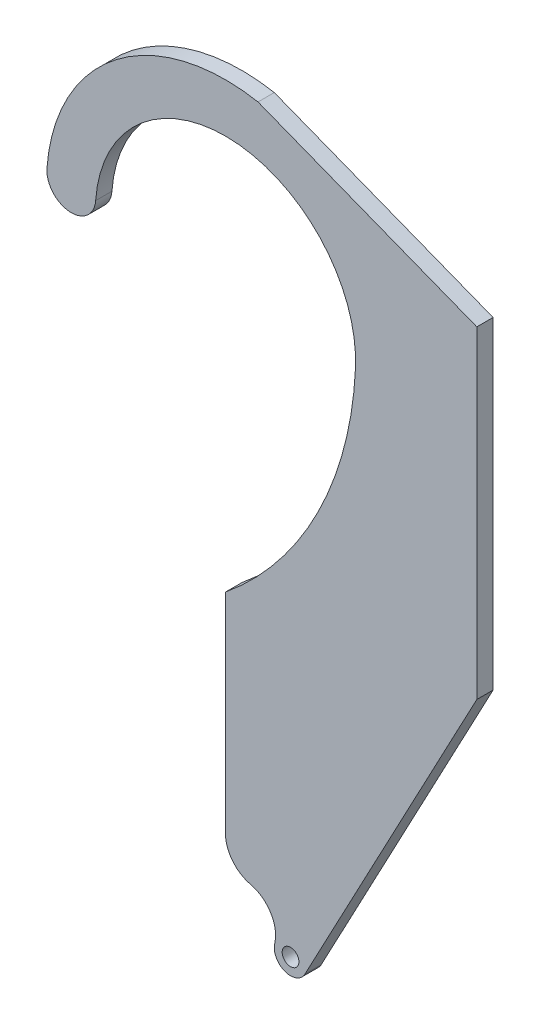
from build123d import *

# Parameters (mm, degrees)
SKETCH1_R             = 6.35
SKETCH1_R_2           = 3.175
BOSS_EXTRUDE1_DEPTH   = 1.5875
F_4_CLEARANCE_HOLE1_D = 3.2639


with BuildPart() as part:
    # Sketch1 → Boss-Extrude1 (new body, symmetric)
    with BuildSketch(Plane.XY):
        with BuildLine():
            Line((49.048701781, -45.301306076), (49.048701781, 17.681627212))
            Line((49.048701781, 17.681627212), (6.35250271, 34.342413053))
            ThreePointArc((6.35250271, 34.342413053), (-21.3593907, 27.632083778), (-34.835067544, 2.504734358))
            ThreePointArc((-34.835067544, 2.504734358), (-30.426385746, -2.587056811), (-25.334594577, 1.821624988))
            ThreePointArc((-25.334594577, 1.821624988), (1.502184662, 25.355540642), (25.372459089, -1.182505722))
            ThreePointArc((25.372459089, -1.182505722), (18.055035291, -29.123378386), (0, -51.667840164))
            Line((0, -51.667840164), (0, -92.444233417))
            ThreePointArc((0, -92.444233417), (6.35, -86.094233417), (12.7, -92.444233417))
            ThreePointArc((12.7, -92.444233417), (10.290303985, -97.423842288), (4.89007732, -98.624130323))
            ThreePointArc((4.89007732, -98.624130323), (8.832322877, -101.466501446), (9.610051547, -106.263949908))
            ThreePointArc((9.610051547, -106.263949908), (13.067449766, -103.840245814), (15.875, -106.993911248))
            ThreePointArc((15.875, -106.993911248), (15.780924606, -107.761067405), (15.504273342, -108.482761819))
            Line((15.504273342, -108.482761819), (49.048701781, -45.301306076))
        make_face()
        with Locations((6.35, -92.444233417)):
            Circle(SKETCH1_R)
        with Locations((12.7, -106.993911248)):
            Circle(SKETCH1_R_2)
    extrude(amount=BOSS_EXTRUDE1_DEPTH, both=True)

    # #4 Clearance Hole1 (through all)
    with Locations(Plane.XY.offset(1.5875)):
        with Locations((12.7, -106.993911248)):
            Hole(F_4_CLEARANCE_HOLE1_D / 2)


solid = part.part
